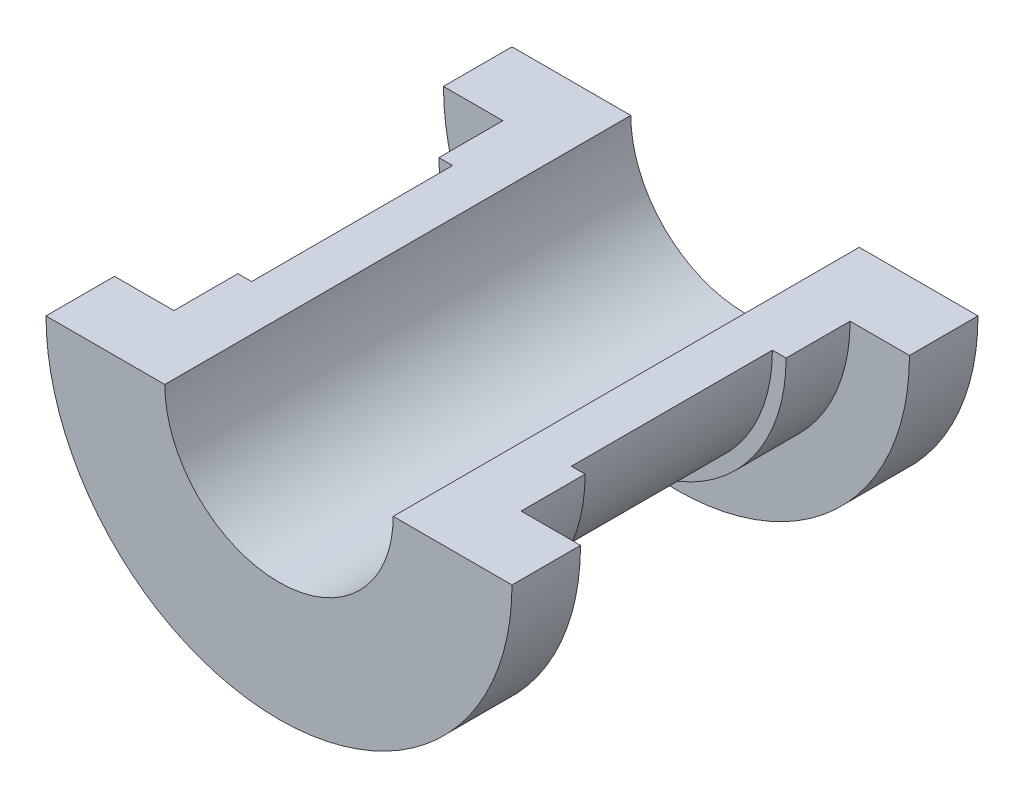
from build123d import *

# Parameters (mm, degrees)
REVOLVE1_ANGLE      = 180
SKETCH2_R           = 3
BOSS_EXTRUDE1_DEPTH = 6


with BuildPart() as part:
    # Sketch1 → Revolve1 (revolve)
    with BuildSketch(Plane(origin=(0, 0, 0), x_dir=(1, 0, 0), z_dir=(0, 1, 0))):
        Polygon((-25.5, 25.5), (-25.5, 18), (-19, 18), (-19, 11), (-17.5, 11), (-17.5, -11), (-19, -11), (-19, -18), (-25.5, -18), (-25.5, -25.5), (-12.5, -25.5), (-12.5, 25.5), align=None)
    revolve(axis=Axis((0, 0, 0), (0, 0, 1)), revolution_arc=REVOLVE1_ANGLE)


with BuildPart() as body_2:
    # Sketch2 → Boss-Extrude1 (new body)
    with BuildSketch(Plane(origin=(0, -17.5, 0), x_dir=(-1, 0, 0), z_dir=(0, -1, 0))):
        with Locations(Location((0, 0, 0), (0, 0, 90))):  # turned: the seam where the file's is
            Circle(SKETCH2_R)
    extrude(amount=BOSS_EXTRUDE1_DEPTH)


solid = Compound([part.part, body_2.part])
